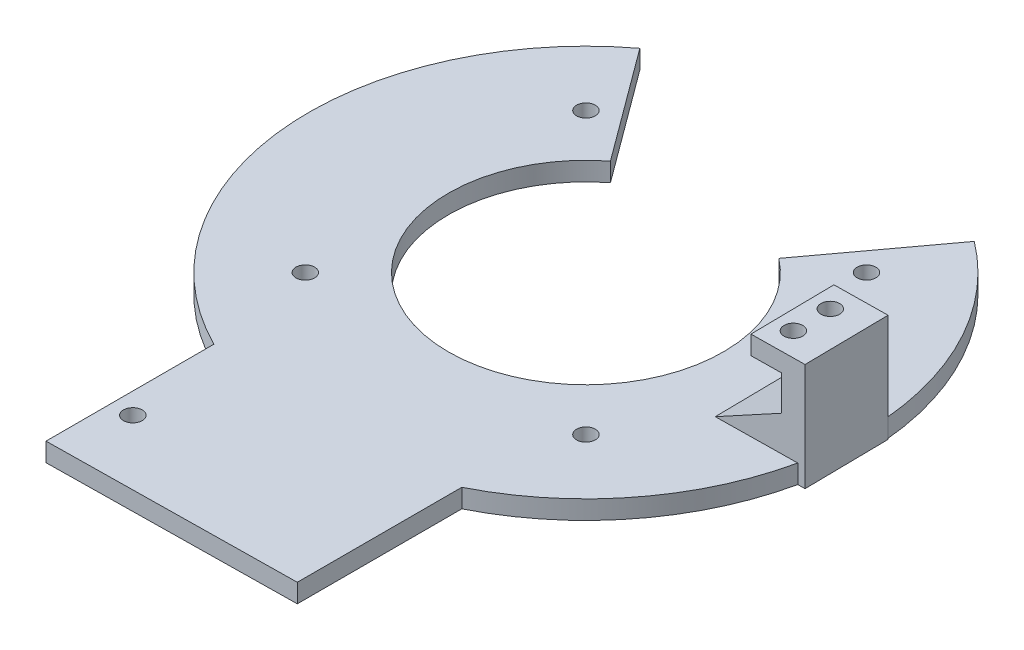
from build123d import *

# Parameters (mm, degrees)
SKETCH1_R                 = 2
BOSS_EXTRUDE1_DEPTH       = 4
F_4_0MM_DOWEL_SLOT1_D     = 4
F_4_0MM_DOWEL_SLOT1_DEPTH = 10.1
F_4_0MM_DOWEL_SLOT1_TIP   = 1.201721238
BOSS_EXTRUDE2_DEPTH       = 18
RIB3_REACH                = 87.328
SKETCH17_WALL_W           = 188.490706902
SKETCH17_WALL_H           = 18
F_4_0MM_DOWEL_HOLE1_D     = 4
F_4_0MM_DOWEL_HOLE1_DEPTH = 4


with BuildPart() as part:
    # Sketch1 → Boss-Extrude1 (new body)
    with BuildSketch(Plane(origin=(0, 0, 0), x_dir=(1, 0, 0), z_dir=(0, 1, 0))):
        with BuildLine():
            Line((-18, 23.245644753), (-35.75, 47.286952746))
            ThreePointArc((-35.75, 47.286952746), (-59.029573825, -5.443143769), (-26.5, -53.027053473))
            Line((-26.5, -53.027053473), (-26.5, -88.937053473))
            Line((-26.5, -88.937053473), (26.5, -88.204553031))
            Line((26.5, -88.204553031), (26.5, -53.027053473))
            ThreePointArc((26.5, -53.027053473), (59.029573825, -5.443143769), (35.75, 47.286952746))
            Line((35.75, 47.286952746), (18, 23.245644753))
            ThreePointArc((18, 23.245644753), (0, -29.4), (-18, 23.245644753))
        make_face()
        with Locations(Location((-22, -74.873523008, 0), (0, 0, 270))):  # turned: the seam where the file's is
            Circle(SKETCH1_R, mode=Mode.SUBTRACT)
    extrude(amount=BOSS_EXTRUDE1_DEPTH)

    # Ø4.0mm Dowel Slot1
    with Locations(Plane(origin=(0, 4, 0), x_dir=(1, 0, 0), z_dir=(0, 1, 0))):
        with Locations((30, 30), (30, -30), (-30, -30), (-30, 30)):
            Hole(F_4_0MM_DOWEL_SLOT1_D / 2, depth=F_4_0MM_DOWEL_SLOT1_DEPTH)
            with Locations((0, 0, -(F_4_0MM_DOWEL_SLOT1_DEPTH + F_4_0MM_DOWEL_SLOT1_TIP / 2))):  # 118° drill point
                Cone(0, F_4_0MM_DOWEL_SLOT1_D / 2, F_4_0MM_DOWEL_SLOT1_TIP, mode=Mode.SUBTRACT)

    # Sketch16 → Boss-Extrude2 (add)
    with BuildSketch(Plane(origin=(0.18548934, 0, 13.421063613), x_dir=(0.999904507, 0, -0.013819443), z_dir=(0.013819443, 0, 0.999904507))):
        Polygon((54.427297978, 0), (59.28, 0), (59.28, 23), (47.86, 23), (47.86, 19), (54.28, 19), (54.28, 4), (54.427297978, 4), align=None)
    extrude(amount=-BOSS_EXTRUDE2_DEPTH)

    # Sketch17 wall → Rib3 (add, up to next)
    with BuildSketch(Plane(origin=(47.366770895, 7.75597266, 3.76812278), x_dir=(-0.880229366, -0.474392522, 0.012165442), z_dir=(0.474347221, -0.88031343, -0.006555841)), mode=Mode.PRIVATE) as rib3_sk1:
        Rectangle(SKETCH17_WALL_W, SKETCH17_WALL_H)
    rib3_tool1 = extrude(rib3_sk1.sketch, amount=RIB3_REACH, mode=Mode.PRIVATE) - part.part
    add(rib3_tool1.solids().sort_by_distance((47.366770895, 7.75597266, 3.76812278))[0])

    # Ø4.0mm Dowel Hole1
    with Locations(Plane(origin=(0, 23, 0), x_dir=(1, 0, 0), z_dir=(0, 1, 0))):
        with Locations((51.970027948, -7.602706454), (51.859461843, 0.397293546)):
            Hole(F_4_0MM_DOWEL_HOLE1_D / 2, depth=F_4_0MM_DOWEL_HOLE1_DEPTH)


solid = part.part
